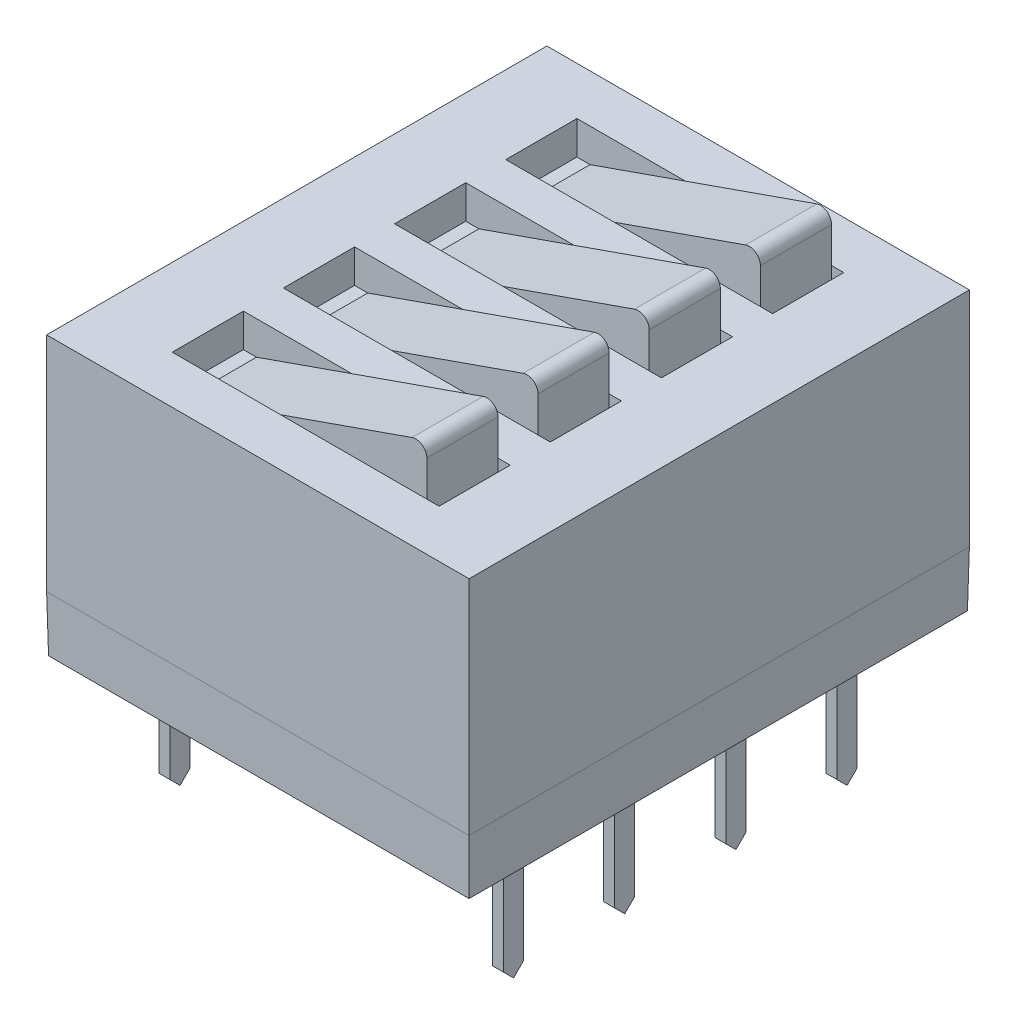
from build123d import *

# Parameters (mm, degrees)
SKETCH1_W                = 11.43
SKETCH1_H                = 9.652
BASE_EXTRUDE_DEPTH       = 6.35
CHAMFER1_SIZE2           = 0.022167932
CHAMFER1_SIZE            = 1.27
BOSS_EXTRUDE_THIN1_DEPTH = 0.635
CUT_EXTRUDE1_DEPTH       = 2.143
CUT_EXTRUDE2_DEPTH       = 2.143
LPATTERN2_COUNT          = 4
LPATTERN2_PITCH          = 2.54
MIRROR1_COPY_1_DEPTH     = 0.635
MIRROR1_COPY_2_DEPTH     = 0.635
MIRROR1_COPY_3_DEPTH     = 0.635
MIRROR1_COPY_4_DEPTH     = 2.143
MIRROR1_COPY_5_DEPTH     = 2.143
MIRROR1_COPY_6_DEPTH     = 2.143
MIRROR1_COPY_7_DEPTH     = 2.143
MIRROR1_COPY_8_DEPTH     = 2.143
MIRROR1_COPY_9_DEPTH     = 2.143
SKETCH6_W                = 6.096
SKETCH6_H                = 1.6256
CUT_EXTRUDE3_DEPTH       = 0.762
BOSS_EXTRUDE1_DEPTH      = 1.6256
LPATTERN3_COUNT          = 4
LPATTERN3_PITCH          = 2.54


with BuildPart() as part:
    # Sketch1 → Base-Extrude (new body)
    with BuildSketch(Plane(origin=(0, 0.381, 0), x_dir=(0, 0, -1), z_dir=(0, 1, 0))):
        with Locations((-3.81, -3.81)):
            Rectangle(SKETCH1_W, SKETCH1_H)
    extrude(amount=BASE_EXTRUDE_DEPTH)

    # Chamfer1
    chamfer1_edges = [part.edges().sort_by_distance(p)[0] for p in [
        (8.636, 0.381, 3.81),
        (3.81, 0.381, 9.525),
        (-1.016, 0.381, 3.81),
        (3.81, 0.381, -1.905),
    ]]
    chamfer(chamfer1_edges, length=CHAMFER1_SIZE, length2=CHAMFER1_SIZE2)

    # Sketch3 → Boss-Extrude-Thin1 (add, symmetric)
    with BuildSketch(Plane(origin=(10.541, 0, 0), x_dir=(-1, 0, 0), z_dir=(0, 0, -1))):
        with BuildLine():
            Line((9.271, 1.8796), (10.033, 1.8796))
            ThreePointArc((10.033, 1.8796), (10.302407684, 1.768007684), (10.414, 1.4986))
            Line((10.414, 1.4986), (10.414, -2.5654))
            Line((10.414, -2.5654), (10.668, -2.5654))
            Line((10.668, -2.5654), (10.668, 1.4986))
            ThreePointArc((10.668, 1.4986), (10.482012806, 1.947612806), (10.033, 2.1336))
            Line((10.033, 2.1336), (9.271, 2.1336))
            Line((9.271, 2.1336), (9.271, 1.8796))
        make_face()
    boss_extrude_thin1 = extrude(amount=BOSS_EXTRUDE_THIN1_DEPTH, both=True)

    # Sketch4 → Cut-Extrude1 (cut, through all)
    with BuildSketch(Plane(origin=(0.127, 0, 0), x_dir=(0, 0, -1), z_dir=(1, 0, 0))):
        Polygon((0.635, -2.5654), (0, -2.5654), (0.2286, -2.3368), (0.2286, -0.0254), (0.635, 0.381), align=None)
    cut_extrude1 = extrude(amount=-CUT_EXTRUDE1_DEPTH, mode=Mode.SUBTRACT)

    # Sketch5 → Cut-Extrude2 (cut, through all)
    with BuildSketch(Plane(origin=(0.127, 0, 0), x_dir=(0, 0, -1), z_dir=(1, 0, 0))):
        Polygon((-0.635, 0.381), (-0.2286, -0.0254), (-0.2286, -2.3368), (0, -2.5654), (-0.635, -2.5654), align=None)
    cut_extrude2 = extrude(amount=-CUT_EXTRUDE2_DEPTH, mode=Mode.SUBTRACT)

    # LPattern2: Boss-Extrude-Thin1, Cut-Extrude1, Cut-Extrude2 ×4
    with Locations(*[(0, 0, i * LPATTERN2_PITCH) for i in range(1, LPATTERN2_COUNT)]):
        add(boss_extrude_thin1)
        add(cut_extrude1, mode=Mode.SUBTRACT)
        add(cut_extrude2, mode=Mode.SUBTRACT)

    # Mirror1: Boss-Extrude-Thin1, Cut-Extrude1, Cut-Extrude2 across plane
    add(boss_extrude_thin1.mirror(Plane.ZY.offset(-3.81)))
    add(cut_extrude1.mirror(Plane.ZY.offset(-3.81)), mode=Mode.SUBTRACT)
    add(cut_extrude2.mirror(Plane.ZY.offset(-3.81)), mode=Mode.SUBTRACT)

    # Mirror1 copy 1 sketch → Mirror1 copy 1 (add, symmetric)
    with BuildSketch(Plane(origin=(-2.921, 0, 2.54), x_dir=(1, 0, 0), z_dir=(0, 0, -1))):
        with BuildLine():
            Line((9.271, -1.8796), (10.033, -1.8796))
            ThreePointArc((10.033, -1.8796), (10.302407684, -1.768007684), (10.414, -1.4986))
            Line((10.414, -1.4986), (10.414, 2.5654))
            Line((10.414, 2.5654), (10.668, 2.5654))
            Line((10.668, 2.5654), (10.668, -1.4986))
            ThreePointArc((10.668, -1.4986), (10.482012806, -1.947612806), (10.033, -2.1336))
            Line((10.033, -2.1336), (9.271, -2.1336))
            Line((9.271, -2.1336), (9.271, -1.8796))
        make_face()
    extrude(amount=MIRROR1_COPY_1_DEPTH, both=True)

    # Mirror1 copy 2 sketch → Mirror1 copy 2 (add, symmetric)
    with BuildSketch(Plane(origin=(-2.921, 0, 5.08), x_dir=(1, 0, 0), z_dir=(0, 0, -1))):
        with BuildLine():
            Line((9.271, -1.8796), (10.033, -1.8796))
            ThreePointArc((10.033, -1.8796), (10.302407684, -1.768007684), (10.414, -1.4986))
            Line((10.414, -1.4986), (10.414, 2.5654))
            Line((10.414, 2.5654), (10.668, 2.5654))
            Line((10.668, 2.5654), (10.668, -1.4986))
            ThreePointArc((10.668, -1.4986), (10.482012806, -1.947612806), (10.033, -2.1336))
            Line((10.033, -2.1336), (9.271, -2.1336))
            Line((9.271, -2.1336), (9.271, -1.8796))
        make_face()
    extrude(amount=MIRROR1_COPY_2_DEPTH, both=True)

    # Mirror1 copy 3 sketch → Mirror1 copy 3 (add, symmetric)
    with BuildSketch(Plane(origin=(-2.921, 0, 7.62), x_dir=(1, 0, 0), z_dir=(0, 0, -1))):
        with BuildLine():
            Line((9.271, -1.8796), (10.033, -1.8796))
            ThreePointArc((10.033, -1.8796), (10.302407684, -1.768007684), (10.414, -1.4986))
            Line((10.414, -1.4986), (10.414, 2.5654))
            Line((10.414, 2.5654), (10.668, 2.5654))
            Line((10.668, 2.5654), (10.668, -1.4986))
            ThreePointArc((10.668, -1.4986), (10.482012806, -1.947612806), (10.033, -2.1336))
            Line((10.033, -2.1336), (9.271, -2.1336))
            Line((9.271, -2.1336), (9.271, -1.8796))
        make_face()
    extrude(amount=MIRROR1_COPY_3_DEPTH, both=True)

    # Mirror1 copy 4 sketch → Mirror1 copy 4 (cut, through all)
    with BuildSketch(Plane(origin=(7.493, 0, 2.54), x_dir=(0, 0, -1), z_dir=(-1, 0, 0))):
        Polygon((0.635, 2.5654), (0, 2.5654), (0.2286, 2.3368), (0.2286, 0.0254), (0.635, -0.381), align=None)
    extrude(amount=-MIRROR1_COPY_4_DEPTH, mode=Mode.SUBTRACT)

    # Mirror1 copy 5 sketch → Mirror1 copy 5 (cut, through all)
    with BuildSketch(Plane(origin=(7.493, 0, 5.08), x_dir=(0, 0, -1), z_dir=(-1, 0, 0))):
        Polygon((0.635, 2.5654), (0, 2.5654), (0.2286, 2.3368), (0.2286, 0.0254), (0.635, -0.381), align=None)
    extrude(amount=-MIRROR1_COPY_5_DEPTH, mode=Mode.SUBTRACT)

    # Mirror1 copy 6 sketch → Mirror1 copy 6 (cut, through all)
    with BuildSketch(Plane(origin=(7.493, 0, 7.62), x_dir=(0, 0, -1), z_dir=(-1, 0, 0))):
        Polygon((0.635, 2.5654), (0, 2.5654), (0.2286, 2.3368), (0.2286, 0.0254), (0.635, -0.381), align=None)
    extrude(amount=-MIRROR1_COPY_6_DEPTH, mode=Mode.SUBTRACT)

    # Mirror1 copy 7 sketch → Mirror1 copy 7 (cut, through all)
    with BuildSketch(Plane(origin=(7.493, 0, 2.54), x_dir=(0, 0, -1), z_dir=(-1, 0, 0))):
        Polygon((-0.635, -0.381), (-0.2286, 0.0254), (-0.2286, 2.3368), (0, 2.5654), (-0.635, 2.5654), align=None)
    extrude(amount=-MIRROR1_COPY_7_DEPTH, mode=Mode.SUBTRACT)

    # Mirror1 copy 8 sketch → Mirror1 copy 8 (cut, through all)
    with BuildSketch(Plane(origin=(7.493, 0, 5.08), x_dir=(0, 0, -1), z_dir=(-1, 0, 0))):
        Polygon((-0.635, -0.381), (-0.2286, 0.0254), (-0.2286, 2.3368), (0, 2.5654), (-0.635, 2.5654), align=None)
    extrude(amount=-MIRROR1_COPY_8_DEPTH, mode=Mode.SUBTRACT)

    # Mirror1 copy 9 sketch → Mirror1 copy 9 (cut, through all)
    with BuildSketch(Plane(origin=(7.493, 0, 7.62), x_dir=(0, 0, -1), z_dir=(-1, 0, 0))):
        Polygon((-0.635, -0.381), (-0.2286, 0.0254), (-0.2286, 2.3368), (0, 2.5654), (-0.635, 2.5654), align=None)
    extrude(amount=-MIRROR1_COPY_9_DEPTH, mode=Mode.SUBTRACT)

    # Sketch6 → Cut-Extrude3 (cut)
    with BuildSketch(Plane(origin=(0, 6.731, 0), x_dir=(-1, 0, 0), z_dir=(0, 1, 0))):
        with Locations((-3.81, 0)):
            Rectangle(SKETCH6_W, SKETCH6_H)
    cut_extrude3 = extrude(amount=-CUT_EXTRUDE3_DEPTH, mode=Mode.SUBTRACT)

    # Sketch7 → Boss-Extrude1 (add)
    with BuildSketch(Plane.XY.offset(-0.8128)):
        with BuildLine():
            Line((1.062579803, 5.969), (6.240649344, 7.782334164))
            ThreePointArc((6.240649344, 7.782334164), (6.471556683, 7.749779505), (6.5786, 7.542608722))
            Line((6.5786, 7.542608722), (6.5786, 5.969))
            Line((6.5786, 5.969), (1.062579803, 5.969))
        make_face()
    boss_extrude1 = extrude(amount=BOSS_EXTRUDE1_DEPTH)

    # LPattern3: Cut-Extrude3, Boss-Extrude1 ×4
    with Locations(*[(0, 0, i * LPATTERN3_PITCH) for i in range(1, LPATTERN3_COUNT)]):
        add(cut_extrude3, mode=Mode.SUBTRACT)
        add(boss_extrude1)


solid = part.part
